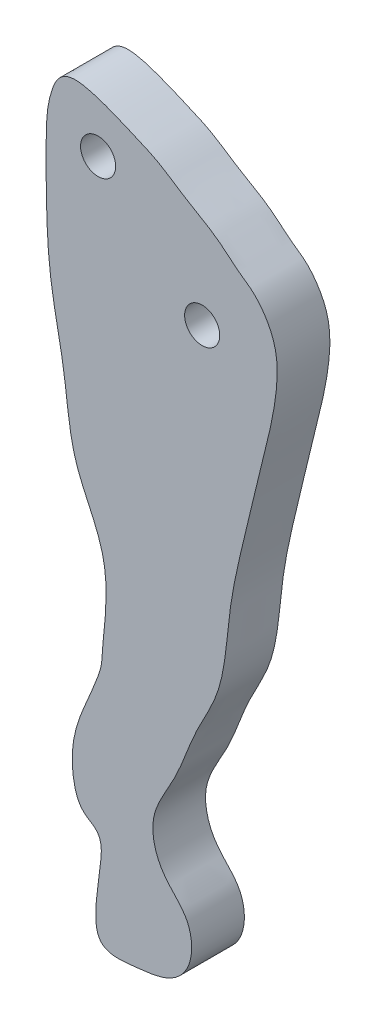
from build123d import *

# Parameters (mm, degrees)
SKETCH1_R           = 1
BOSS_EXTRUDE1_DEPTH = 3


with BuildPart() as part:
    # Sketch1 → Boss-Extrude1 (new body)
    with BuildSketch(Plane.XY):
        with BuildLine():
            add(Edge.make_bspline(
                [(-15.468204456, 11.712747055), (-15.272446323, 12.256811839), (-14.694261771, 13.375456495), (-10.747210876, 11.685620072), (-9.378859991, 11.101105577), (-7.935606405, 10.0666802), (-6.0861698, 9.076651678), (-5.224146094, 8.240554648), (-4.468119126, 7.688143182), (-3.819649337, 7.264924706), (-2.650882753, 5.657730413), (-2.629864215, 3.30204689), (-3.102059643, 0.907695055), (-3.699438781, -1.346847144), (-4.470747658, -4.729915828), (-5.527828981, -8.847764056), (-5.631350788, -13.044529764), (-7.507808601, -16.094030577), (-8.348893228, -18.859439282), (-10.099175378, -21.277304553), (-9.407739302, -23.948432017), (-7.568034127, -25.277618233), (-7.421300252, -27.700715999), (-8.693877337, -29.04436701), (-11.019423571, -29.275771778), (-13.274059344, -29.54175631), (-12.746965546, -24.986134625), (-12.448721016, -23.677448978), (-14.126669743, -22.990564433), (-14.567295733, -19.967840926), (-12.467343692, -15.142880915), (-12.844575476, -15.732097737), (-12.03447618, -9.801403815), (-14.453523921, -6.348190438), (-14.683080959, -1.98597908), (-15.708635077, 2.219227766), (-15.837753695, 5.990247985), (-15.844145609, 9.526404854), (-15.75446731, 10.917145179), (-15.468204456, 11.712747055)],
                knots=[0, 0, 0, 0, 0.019167673, 0.035852014, 0.04922113, 0.065362599, 0.08061576, 0.09473419, 0.096820482, 0.101478682, 0.125428179, 0.150735164, 0.177782922, 0.196742022, 0.232864058, 0.285139057, 0.334734415, 0.362743594, 0.397641911, 0.42772934, 0.45292082, 0.47629891, 0.496976086, 0.520565297, 0.535628386, 0.556474129, 0.575336841, 0.609704642, 0.622665552, 0.634741166, 0.653971369, 0.715131704, 0.757143736, 0.804519559, 0.849469401, 0.89291477, 0.942684833, 0.97197055, 1, 1, 1, 1], degree=3))
        make_face()
        with Locations((-6.947071349, 4.289934103)):
            Circle(SKETCH1_R, mode=Mode.SUBTRACT)
        with Locations((-12.874737023, 9.662343215)):
            Circle(SKETCH1_R, mode=Mode.SUBTRACT)
    extrude(amount=BOSS_EXTRUDE1_DEPTH)


solid = part.part
